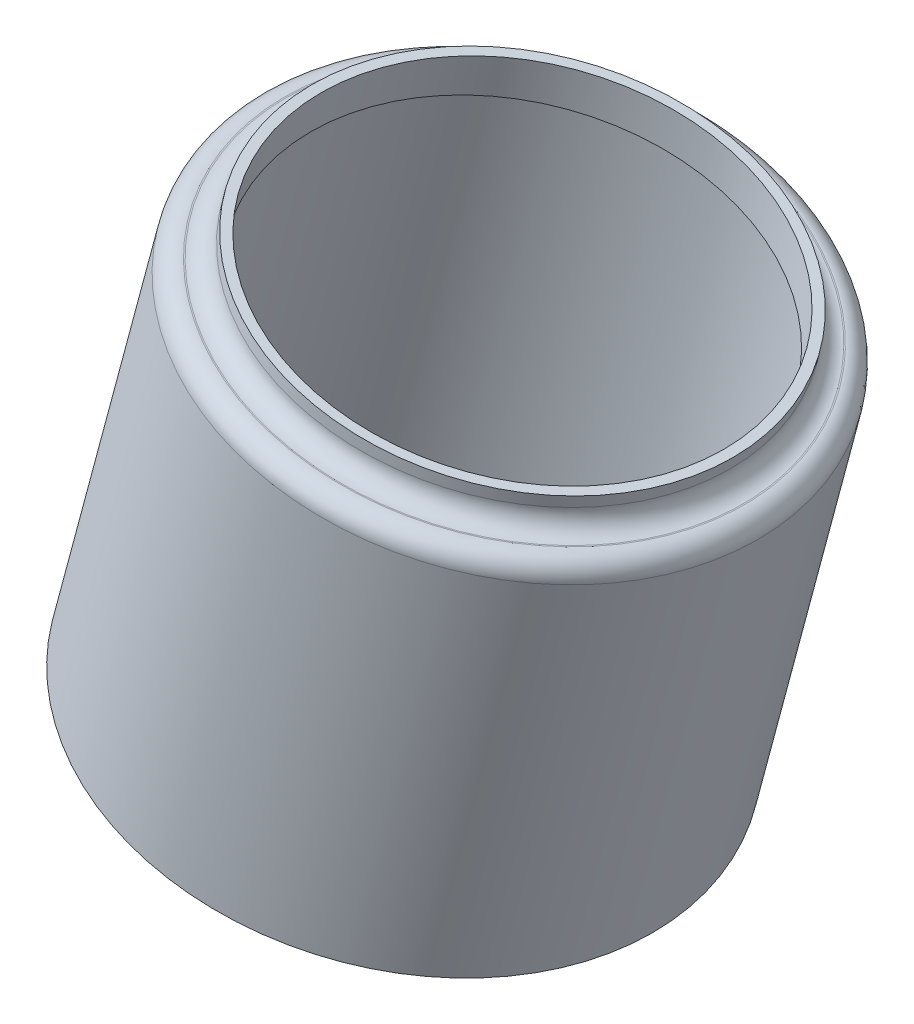
from build123d import *


with BuildPart() as part:
    # Sketch1 → Revolve1 (revolve)
    with BuildSketch(Plane.XY):
        with BuildLine():
            Line((114.170121614, -21.739380235), (117.046248252, -11.00552949))
            Line((117.046248252, -11.00552949), (116.034199468, -10.734351836))
            Line((116.034199468, -10.734351836), (116.313594627, -9.691634906))
            Line((116.313594627, -9.691634906), (116.558939787, -9.757374944))
            Line((116.558939787, -9.757374944), (116.47676474, -10.064056394))
            ThreePointArc((116.47676474, -10.064056394), (116.527514155, -10.449536469), (116.835974985, -10.686226788))
            Line((116.835974985, -10.686226788), (116.86664313, -10.694444293))
            ThreePointArc((116.86664313, -10.694444293), (117.17510396, -10.931134613), (117.225853375, -11.316614688))
            Line((117.225853375, -11.316614688), (114.415466774, -21.805120272))
            Line((114.415466774, -21.805120272), (114.170121614, -21.739380235))
        make_face()
    revolve(axis=Axis((111.07814933, -7.762881267, 0), (-0.258819045, -0.965925826, 0)))


solid = part.part
